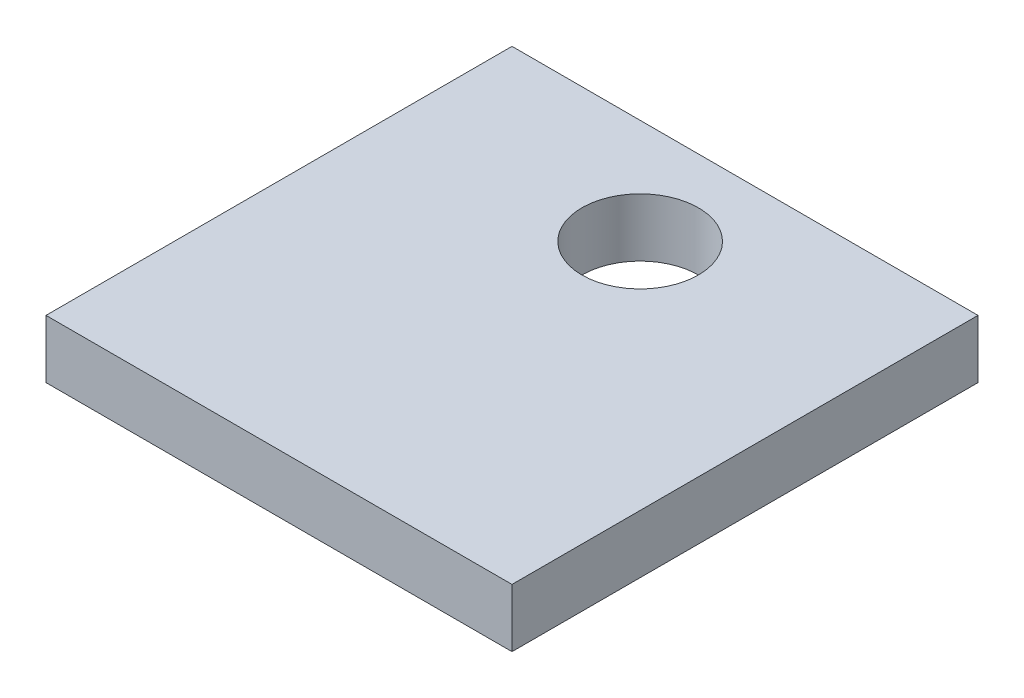
from build123d import *

# Parameters (mm, degrees)
SKETCH1_W           = 80
SKETCH1_H           = 80
BOSS_EXTRUDE1_DEPTH = 5
SKETCH2_R           = 10
CUT_EXTRUDE1_DEPTH  = 11


with BuildPart() as part:
    # Sketch1 → Boss-Extrude1 (new body, symmetric)
    with BuildSketch(Plane(origin=(0, 0, 0), x_dir=(1, 0, 0), z_dir=(0, 1, 0))):
        Rectangle(SKETCH1_W, SKETCH1_H)
    extrude(amount=BOSS_EXTRUDE1_DEPTH, both=True)

    # Sketch2 → Cut-Extrude1 (cut, through all)
    with BuildSketch(Plane(origin=(0, 5, 0), x_dir=(1, 0, 0), z_dir=(0, 1, 0))):
        with Locations((0, 22)):
            Circle(SKETCH2_R)
    extrude(amount=-CUT_EXTRUDE1_DEPTH, mode=Mode.SUBTRACT)


solid = part.part
